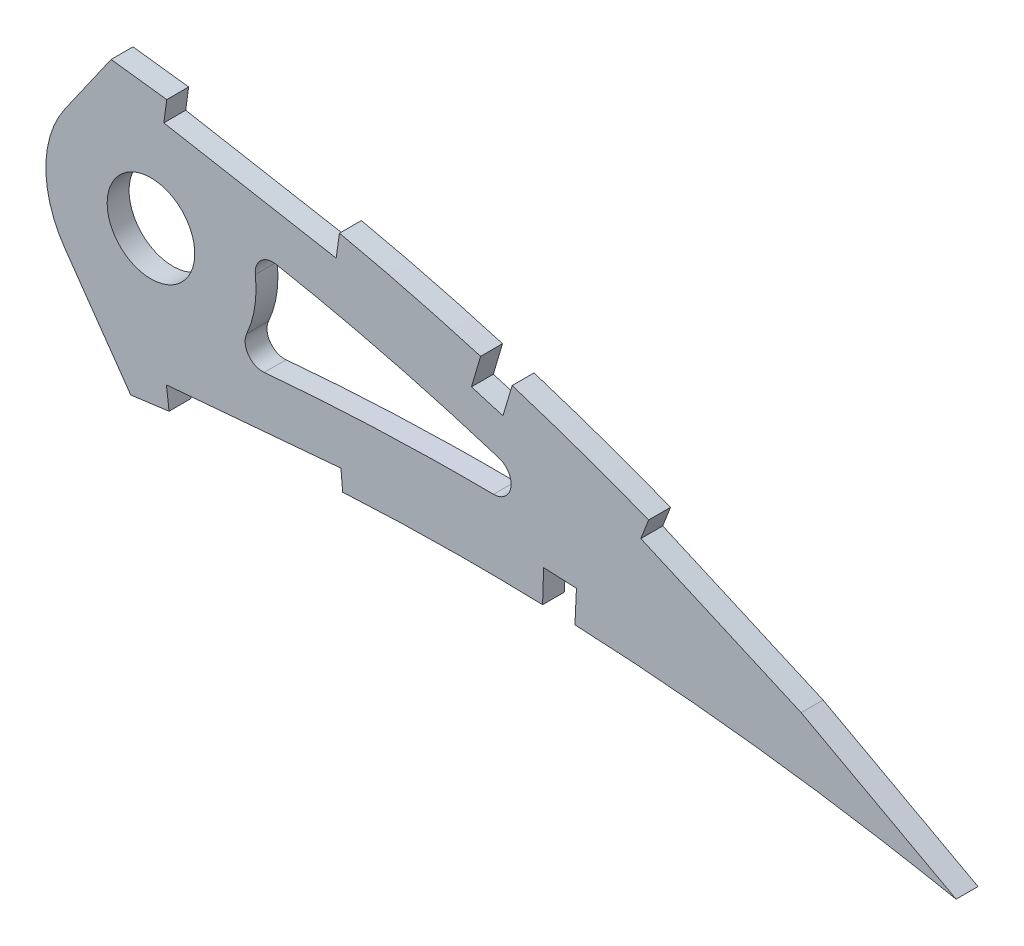
from build123d import *

# Parameters (mm, degrees)
BOSS_EXTRUDE1_DEPTH = 3.175
SKETCH3_R           = 6.35
CUT_EXTRUDE2_DEPTH  = 7.62
CUT_EXTRUDE6_DEPTH  = 408.776579698
CUT_EXTRUDE8_DEPTH  = 408.049338342
FILLET1_R           = 2.54


with BuildPart() as part:
    # Sketch1 → Boss-Extrude1 (new body)
    with BuildSketch(Plane.XY):
        with BuildLine():
            Line((400.787296687, -0.625618575), (404.58872131, -1.413553637))
            Line((404.58872131, -1.413553637), (401.287791605, 0.625618575))
            add(Edge.make_bspline(
                [(401.287791605, 0.625618575), (401.25705042, 0.644609155), (401.134204912, 0.72049782), (400.857411484, 0.890278961), (400.396493038, 1.173058239), (399.751247531, 1.566871371), (398.922175851, 2.070672454), (397.908860973, 2.68093382), (396.711935531, 3.395672751), (395.331689394, 4.211509244), (393.768263549, 5.124622449), (392.022253727, 6.13131418), (390.093811539, 7.225884301), (387.983684209, 8.40386082), (385.692595708, 9.659641163), (383.220979472, 10.987553753), (380.56972033, 12.38084365), (377.739836141, 13.833518373), (374.731843022, 15.337556147), (371.54715891, 16.88669721), (368.186844821, 18.473217451), (364.65204792, 20.088652961), (360.944798752, 21.726417866), (357.066122369, 23.376330622), (353.018229116, 25.031242761), (348.802842216, 26.681735695), (344.422457593, 28.32029276), (339.878765312, 29.936298907), (335.175161908, 31.522692312), (330.313928957, 33.069166923), (325.298542897, 34.56732415), (320.131917844, 36.007450609), (314.818360762, 37.382160583), (309.361241544, 38.681442748), (303.765185385, 39.896600345), (298.03464057, 41.02031727), (292.174413061, 42.04137478), (286.200742138, 42.958976846), (280.209742812, 43.722266376), (274.231069525, 44.470878511), (268.261299999, 45.17413112), (262.218567362, 45.847592765), (256.10868514, 46.487471701), (249.937713774, 47.091767095), (243.711900539, 47.657870828), (237.437715133, 48.184122735), (231.121228788, 48.667540922), (224.769101889, 49.107380553), (218.387614357, 49.499774963), (211.98356324, 49.844429477), (205.563449499, 50.138940399), (199.133954308, 50.381278445), (192.701904891, 50.569980712), (186.273977921, 50.703239355), (179.85713322, 50.780216544), (173.458045294, 50.79880892), (167.083670719, 50.758683916), (160.740684507, 50.658463796), (154.436050312, 50.496776579), (148.176452254, 50.273320497), (141.968659113, 49.988192458), (135.819467799, 49.639004764), (129.735549083, 49.227982621), (123.723677901, 48.753399501), (117.790459605, 48.215129125), (111.942112261, 47.615415217), (106.185147076, 46.95262669), (100.525733772, 46.228649337), (94.970062623, 45.44490258), (89.52436722, 44.600959597), (84.194481144, 43.69925796), (78.986156841, 42.740720338), (73.90490471, 41.728156841), (68.956256893, 40.661831591), (64.145451771, 39.544943342), (59.477489064, 38.379437887), (54.957386691, 37.167448987), (50.589726748, 35.911884874), (46.378925887, 34.615594017), (42.329892905, 33.280000791), (38.445687963, 31.910169164), (34.73108241, 30.507071575), (31.188921766, 29.075030523), (27.823357151, 27.616001391), (24.636902803, 26.134431982), (21.633165033, 24.632009073), (18.814284614, 23.11294194), (16.183091514, 21.579559842), (13.742118495, 20.034710979), (11.492391543, 18.482313842), (9.437012349, 16.923342928), (7.576687012, 15.361737611), (5.912592814, 13.799875814), (4.44710834, 12.23883351), (3.180180906, 10.681359637), (2.113470886, 9.128687662), (1.247163293, 7.582286813), (0.583217576, 6.043280407), (0.120975432, 4.512533928), (-0.132052878, 2.992306743), (-0.195033127, 1.481380095), (-0.064913904, 0.493055549), (0, 0)],
                knots=[0, 0, 0, 0, 0.00025409, 0.001015373, 0.002283359, 0.004056577, 0.006330981, 0.009105275, 0.01237449, 0.016134023, 0.020379661, 0.025105976, 0.030306237, 0.035972206, 0.042099523, 0.048678063, 0.055701664, 0.063160184, 0.071045824, 0.079349826, 0.08806291, 0.097175756, 0.106678112, 0.116561573, 0.126814275, 0.137428301, 0.148393618, 0.15969976, 0.171338125, 0.183297699, 0.195569604, 0.208143556, 0.221011593, 0.234161831, 0.24758745, 0.261276822, 0.27522271, 0.289414144, 0.3037712, 0.317689227, 0.331784111, 0.346039677, 0.36044387, 0.37498272, 0.389640454, 0.404403317, 0.419256601, 0.434186749, 0.449177265, 0.464214782, 0.479284009, 0.49436974, 0.509457833, 0.524532346, 0.53957932, 0.554582984, 0.569529546, 0.584403417, 0.599190992, 0.613876838, 0.628447475, 0.642888675, 0.657186054, 0.671325546, 0.685294014, 0.699078147, 0.712665095, 0.726042645, 0.739197713, 0.752117586, 0.764792042, 0.777208152, 0.789355685, 0.80122396, 0.812803686, 0.824082909, 0.835054602, 0.845709571, 0.856037853, 0.866033834, 0.875688843, 0.884997719, 0.893953426, 0.902552897, 0.910789386, 0.918660734, 0.926166253, 0.933302626, 0.94007122, 0.94647478, 0.952517526, 0.958204819, 0.963546652, 0.9685566, 0.973249913, 0.977651041, 0.981787043, 0.985694226, 0.989415109, 0.993001157, 0.996508416, 1, 1, 1, 1], degree=3))
            add(Edge.make_bspline(
                [(0, 0), (0.103049284, -0.48646135), (0.309621448, -1.461619734), (0.870851066, -2.865443777), (1.613050436, -4.214925318), (2.551796624, -5.50647982), (3.680847847, -6.739754318), (4.997710545, -7.916031475), (6.501093168, -9.034678962), (8.189028138, -10.095187575), (10.059063445, -11.09868312), (12.109097167, -12.044541691), (14.337260098, -12.932467688), (16.741124572, -13.761274257), (19.317751853, -14.532223507), (22.064692152, -15.243436854), (24.97882197, -15.895908217), (28.05733844, -16.487972167), (31.296886955, -17.020230139), (34.694102049, -17.492384374), (38.245496748, -17.904730047), (41.947586851, -18.256402054), (45.796710627, -18.548156683), (49.789031596, -18.780187571), (53.920674484, -18.953230456), (58.187681625, -19.066627473), (62.58587396, -19.122146552), (67.111276761, -19.120621113), (71.759463099, -19.061643238), (76.526462331, -18.948470974), (81.407699994, -18.780387546), (86.398769299, -18.559426901), (91.495168248, -18.287812779), (96.692325919, -17.966465898), (101.985668646, -17.596810448), (107.37060035, -17.181810955), (112.842229312, -16.722502456), (118.395783547, -16.221562258), (124.026346455, -15.681498051), (129.729053332, -15.104019149), (135.498870515, -14.49184199), (141.330658933, -13.846950334), (147.21945752, -13.172784637), (153.159886908, -12.470564744), (159.146923795, -11.74429993), (165.174935894, -10.995377793), (171.238882573, -10.22668305), (177.333309878, -9.441834962), (183.452512414, -8.640744143), (189.591343474, -7.829117957), (195.743882981, -7.00628799), (201.904775565, -6.176486019), (208.06831816, -5.342291406), (214.22850741, -4.503960799), (220.379928291, -3.664968493), (226.516874304, -2.827617677), (232.633334198, -1.991984907), (238.723774215, -1.162223511), (244.78206143, -0.338232212), (250.802609447, 0.478318572), (256.779648968, 1.284991388), (262.707540904, 2.080768094), (268.580170325, 2.865145364), (274.391628816, 3.638417632), (280.049067093, 4.37711422), (285.537702193, 5.120570933), (290.876029706, 5.730040641), (296.14788831, 6.250245022), (301.358754097, 6.676740793), (306.50237003, 7.015663982), (311.572842567, 7.269436368), (316.564128762, 7.441600876), (321.469923946, 7.537265082), (326.284100572, 7.558856566), (331.000087643, 7.513261133), (335.611751442, 7.404154135), (340.112655635, 7.236432817), (344.496521024, 7.015755786), (348.757120789, 6.748138962), (352.888058537, 6.437529801), (356.883577893, 6.091179644), (360.737514312, 5.714158782), (364.44395011, 5.310774515), (367.997477022, 4.889479588), (371.39240732, 4.453047621), (374.623634344, 4.008650917), (377.685956779, 3.560792785), (380.574524742, 3.11519123), (383.284799906, 2.676097091), (385.812404301, 2.249338393), (388.153378523, 1.838902367), (390.303660314, 1.448797258), (392.26026659, 1.083945061), (394.019333118, 0.746158195), (395.578507255, 0.441003535), (396.934889863, 0.169827429), (398.086492502, -0.063549443), (399.031304118, -0.25820606), (399.767889713, -0.41094701), (400.294794442, -0.522016373), (400.611448368, -0.58810827), (400.752141787, -0.618119663), (400.787296687, -0.625618575)],
                knots=[0, 0, 0, 0, 0.003638255, 0.007293231, 0.011028136, 0.014901081, 0.018963272, 0.023258475, 0.027820626, 0.032679082, 0.03785316, 0.043361875, 0.049214679, 0.055422346, 0.061988786, 0.068918036, 0.076211157, 0.083868392, 0.091887411, 0.100265912, 0.108999867, 0.118084529, 0.127514843, 0.13728527, 0.147387917, 0.157816481, 0.168563473, 0.179619128, 0.190977373, 0.202626974, 0.214560478, 0.226767249, 0.239236417, 0.251959004, 0.264923894, 0.278119703, 0.291536035, 0.30516028, 0.318980685, 0.332985499, 0.34716279, 0.361498603, 0.375980747, 0.390597192, 0.405332593, 0.420174823, 0.435109533, 0.450124276, 0.465203068, 0.480333154, 0.495500583, 0.510689775, 0.525887334, 0.541078314, 0.556247233, 0.571381784, 0.58646604, 0.601484516, 0.616424329, 0.631269422, 0.646006524, 0.660620684, 0.675098187, 0.689422858, 0.703581825, 0.716907563, 0.730009275, 0.742952128, 0.755725558, 0.768319952, 0.780724338, 0.792926529, 0.804916041, 0.816679084, 0.828203524, 0.8394749, 0.850481359, 0.861207697, 0.871639326, 0.881763414, 0.891563605, 0.901027365, 0.910138977, 0.918883977, 0.927249278, 0.935221104, 0.942784738, 0.949928188, 0.956638464, 0.962904203, 0.968712288, 0.974054485, 0.978918432, 0.983297218, 0.987180246, 0.990560674, 0.993433357, 0.995790625, 0.997629587, 0.998945816, 0.999736592, 1, 1, 1, 1], degree=3))
        make_face()
    extrude(amount=BOSS_EXTRUDE1_DEPTH)

    # Sketch3 → Cut-Extrude2 (cut)
    with BuildSketch(Plane(origin=(0, 0, 0), x_dir=(-1, 0, 0), z_dir=(0, 0, -1))):
        with Locations((-279.074525609, 26.255421435)):
            Circle(SKETCH3_R)
    extrude(amount=-CUT_EXTRUDE2_DEPTH, mode=Mode.SUBTRACT)

    # Sketch4 → Cut-Extrude6 (cut, through all)
    with BuildSketch(Plane.XY.offset(3.175)):
        with BuildLine():
            ThreePointArc((266.590648454, 17.514116545), (263.834525609, 26.255421435), (266.590648454, 34.996726325))
            Line((266.590648454, 34.996726325), (266.678819026, 35.122646952))
            Line((266.678819026, 35.122646952), (273.298363259, 44.576335854))
            add(Edge.make_bspline(
                [(273.298363259, 44.576335854), (271.627249364, 44.77745292), (267.942024962, 45.209714275), (262.218567362, 45.847592765), (256.10868514, 46.487471701), (249.937713774, 47.091767095), (243.711900539, 47.657870828), (237.437715133, 48.184122735), (231.121228788, 48.667540922), (224.769101889, 49.107380553), (218.387614357, 49.499774963), (211.98356324, 49.844429477), (205.563449499, 50.138940399), (199.133954308, 50.381278445), (192.701904891, 50.569980712), (186.273977921, 50.703239355), (179.85713322, 50.780216544), (173.458045294, 50.79880892), (167.083670719, 50.758683916), (161.240890559, 50.666367125), (157.524085212, 50.575387547), (155.922048169, 50.530055295)],
                knots=[0.31994822, 0.31994822, 0.31994822, 0.31994822, 0.331784111, 0.346039677, 0.36044387, 0.37498272, 0.389640454, 0.404403317, 0.419256601, 0.434186749, 0.449177265, 0.464214782, 0.479284009, 0.49436974, 0.509457833, 0.524532346, 0.53957932, 0.554582984, 0.569529546, 0.584403417, 0.595673217, 0.595673217, 0.595673217, 0.595673217], degree=3))
            add(Edge.make_bspline(
                [(155.922048169, 50.530055295), (155.421985617, 50.515905209), (152.834371808, 50.439599617), (148.176452254, 50.273320497), (141.968659113, 49.988192458), (135.819467799, 49.639004764), (129.735549083, 49.227982621), (123.723677901, 48.753399501), (117.790459605, 48.215129125), (111.942112261, 47.615415217), (106.185147076, 46.95262669), (100.525733772, 46.228649337), (94.970062623, 45.44490258), (89.52436722, 44.600959597), (84.194481144, 43.69925796), (78.986156841, 42.740720338), (73.90490471, 41.728156841), (68.956256893, 40.661831591), (64.145451771, 39.544943342), (59.477489064, 38.379437887), (54.957386691, 37.167448987), (50.589726748, 35.911884874), (46.378925887, 34.615594017), (42.329892905, 33.280000791), (38.445687963, 31.910169164), (34.73108241, 30.507071575), (31.188921766, 29.075030523), (27.823357151, 27.616001391), (24.636902803, 26.134431982), (21.633165033, 24.632009073), (18.814284614, 23.11294194), (16.183091514, 21.579559842), (13.742118495, 20.034710979), (11.492391543, 18.482313842), (9.437012349, 16.923342928), (7.576687012, 15.361737611), (5.912592814, 13.799875814), (4.44710834, 12.23883351), (3.180180906, 10.681359637), (2.113470886, 9.128687662), (1.247163293, 7.582286813), (0.583217576, 6.043280407), (0.120975432, 4.512533928), (-0.132052878, 2.992306743), (-0.195033127, 1.481380095), (-0.064913904, 0.493055549), (0, 0)],
                knots=[0.595673217, 0.595673217, 0.595673217, 0.595673217, 0.599190992, 0.613876838, 0.628447475, 0.642888675, 0.657186054, 0.671325546, 0.685294014, 0.699078147, 0.712665095, 0.726042645, 0.739197713, 0.752117586, 0.764792042, 0.777208152, 0.789355685, 0.80122396, 0.812803686, 0.824082909, 0.835054602, 0.845709571, 0.856037853, 0.866033834, 0.875688843, 0.884997719, 0.893953426, 0.902552897, 0.910789386, 0.918660734, 0.926166253, 0.933302626, 0.94007122, 0.94647478, 0.952517526, 0.958204819, 0.963546652, 0.9685566, 0.973249913, 0.977651041, 0.981787043, 0.985694226, 0.989415109, 0.993001157, 0.996508416, 1, 1, 1, 1], degree=3))
            add(Edge.make_bspline(
                [(0, 0), (0.103049284, -0.48646135), (0.309621448, -1.461619734), (0.870851066, -2.865443777), (1.613050436, -4.214925318), (2.551796624, -5.50647982), (3.680847847, -6.739754318), (4.997710545, -7.916031475), (6.501093168, -9.034678962), (8.189028138, -10.095187575), (10.059063445, -11.09868312), (12.109097167, -12.044541691), (14.337260098, -12.932467688), (16.741124572, -13.761274257), (19.317751853, -14.532223507), (22.064692152, -15.243436854), (24.97882197, -15.895908217), (28.05733844, -16.487972167), (31.296886955, -17.020230139), (34.694102049, -17.492384374), (38.245496748, -17.904730047), (41.947586851, -18.256402054), (45.796710627, -18.548156683), (49.789031596, -18.780187571), (53.920674484, -18.953230456), (58.187681625, -19.066627473), (62.58587396, -19.122146552), (67.111276761, -19.120621113), (71.759463099, -19.061643238), (76.526462331, -18.948470974), (81.407699994, -18.780387546), (86.398769299, -18.559426901), (91.495168248, -18.287812779), (96.692325919, -17.966465898), (101.985668646, -17.596810448), (107.37060035, -17.181810955), (112.842229312, -16.722502456), (118.395783547, -16.221562258), (124.026346455, -15.681498051), (129.729053332, -15.104019149), (135.498870515, -14.49184199), (141.330658933, -13.846950334), (147.21945752, -13.172784637), (153.159886908, -12.470564744), (159.146923795, -11.74429993), (165.087519012, -11.006238494), (169.031390588, -10.506510457), (170.965654904, -10.25953821)],
                knots=[0, 0, 0, 0, 0.003638255, 0.007293231, 0.011028136, 0.014901081, 0.018963272, 0.023258475, 0.027820626, 0.032679082, 0.03785316, 0.043361875, 0.049214679, 0.055422346, 0.061988786, 0.068918036, 0.076211157, 0.083868392, 0.091887411, 0.100265912, 0.108999867, 0.118084529, 0.127514843, 0.13728527, 0.147387917, 0.157816481, 0.168563473, 0.179619128, 0.190977373, 0.202626974, 0.214560478, 0.226767249, 0.239236417, 0.251959004, 0.264923894, 0.278119703, 0.291536035, 0.30516028, 0.318980685, 0.332985499, 0.34716279, 0.361498603, 0.375980747, 0.390597192, 0.405332593, 0.420174823, 0.434464025, 0.434464025, 0.434464025, 0.434464025], degree=3))
            add(Edge.make_bspline(
                [(170.965654904, -10.25953821), (171.053034392, -10.248381354), (173.172879776, -9.977620434), (177.333309878, -9.441834962), (183.452512414, -8.640744143), (189.591343474, -7.829117957), (195.743882981, -7.00628799), (201.904775565, -6.176486019), (208.06831816, -5.342291406), (214.22850741, -4.503960799), (220.379928291, -3.664968493), (226.516874304, -2.827617677), (232.633334198, -1.991984907), (238.723774215, -1.162223511), (244.78206143, -0.338232212), (250.802609447, 0.478318572), (256.779648968, 1.284991388), (262.707540904, 2.080768094), (268.580170325, 2.865145364), (273.053598122, 3.46037936), (275.569135879, 3.791009193), (276.146544657, 3.86688243)],
                knots=[0.434464025, 0.434464025, 0.434464025, 0.434464025, 0.435109533, 0.450124276, 0.465203068, 0.480333154, 0.495500583, 0.510689775, 0.525887334, 0.541078314, 0.556247233, 0.571381784, 0.58646604, 0.601484516, 0.616424329, 0.631269422, 0.646006524, 0.660620684, 0.675098187, 0.689422858, 0.693690448, 0.693690448, 0.693690448, 0.693690448], degree=3))
            Line((276.146544657, 3.86688243), (269.578307971, 13.247296561))
            Line((269.578307971, 13.247296561), (266.590648454, 17.514116545))
        make_face()
        with BuildLine():
            add(Edge.make_bspline(
                [(345.280778699, 17.138524199), (343.784100238, 17.712102169), (337.492980243, 20.063101429), (326.275084115, 23.810337857), (311.484657452, 27.867535323), (300.490953316, 30.234986898), (294.415102434, 31.333564105), (293.37827515, 31.514732137)],
                knots=[0.137249706, 0.137249706, 0.137249706, 0.137249706, 0.148918304, 0.18614788, 0.223377457, 0.260607033, 0.268267562, 0.268267562, 0.268267562, 0.268267562], degree=3))
            ThreePointArc((293.37827515, 31.514732137), (294.078637429, 28.926419094), (294.314525609, 26.255421435))
            ThreePointArc((294.314525609, 26.255421435), (293.254677636, 20.671436433), (290.222545491, 15.864114842))
            add(Edge.make_bspline(
                [(290.222545491, 15.864114842), (290.774126105, 15.922150342), (293.793472526, 16.232317616), (301.792459866, 16.94651902), (314.205368487, 17.632888547), (329.126934502, 17.796918069), (339.481884573, 17.460650141), (344.860745729, 17.16255365), (345.280778699, 17.138524199)],
                knots=[0.730956873, 0.730956873, 0.730956873, 0.730956873, 0.734905012, 0.752578011, 0.787924009, 0.823270008, 0.858616006, 0.861610406, 0.861610406, 0.861610406, 0.861610406], degree=3))
        make_face()
    extrude(amount=-CUT_EXTRUDE6_DEPTH, mode=Mode.SUBTRACT)

    # Sketch5 → Cut-Extrude8 (cut, through all)
    with BuildSketch(Plane.XY.offset(3.175)):
        with BuildLine():
            add(Edge.make_bspline(
                [(281.428214874, 43.565668026), (281.407899795, 43.568254047), (281.387584623, 43.570839337), (281.367269359, 43.57342392)],
                knots=[0.300745518, 0.300745518, 0.300745518, 0.300745518, 0.300889521, 0.300889521, 0.300889521, 0.300889521], degree=3))
            Line((281.367269359, 43.57342392), (280.936730544, 40.431239395))
            Line((280.936730544, 40.431239395), (305.92678033, 35.942589702))
            Line((305.92678033, 35.942589702), (306.369250913, 39.086545718))
            Line((306.369250913, 39.086545718), (281.428214874, 43.565668026))
        make_face()
        with BuildLine():
            add(Edge.make_bspline(
                [(306.410670798, 39.317183503), (305.540638719, 39.505504323), (302.765071766, 40.092715137), (298.03464057, 41.02031727), (292.174413061, 42.04137478), (286.626079059, 42.893641805), (283.026780842, 43.362177559), (281.428214874, 43.565668026)],
                knots=[0.241327911, 0.241327911, 0.241327911, 0.241327911, 0.24758745, 0.261276822, 0.27522271, 0.289414144, 0.300745518, 0.300745518, 0.300745518, 0.300745518], degree=3))
            Line((281.428214874, 43.565668026), (306.369250913, 39.086545718))
            Line((306.369250913, 39.086545718), (306.410670798, 39.317183503))
        make_face()
        with BuildLine():
            Line((330.109691414, 28.237455749), (331.441621686, 32.702939814))
            add(Edge.make_bspline(
                [(331.441621686, 32.702939814), (331.078592447, 32.816498368), (329.559030125, 33.288566804), (328.035627369, 33.748190522), (326.874240224, 34.090635015)],
                knots=[0.180622976, 0.180622976, 0.180622976, 0.180622976, 0.183297699, 0.191811938, 0.191811938, 0.191811938, 0.191811938], degree=3))
            Line((326.874240224, 34.090635015), (325.542932248, 29.587605098))
            Line((325.542932248, 29.587605098), (330.109691414, 28.237455749))
        make_face()
        with BuildLine():
            add(Edge.make_bspline(
                [(395.814804403, 0.393165288), (396.210888149, 0.314563813), (396.991244968, 0.158406842), (398.086492502, -0.063549443), (399.031304118, -0.25820606), (399.767889713, -0.41094701), (400.294794442, -0.522016373), (400.611448368, -0.58810827), (400.752141787, -0.618119663), (400.787296687, -0.625618575)],
                knots=[0.987601606, 0.987601606, 0.987601606, 0.987601606, 0.990560674, 0.993433357, 0.995790625, 0.997629587, 0.998945816, 0.999736592, 1, 1, 1, 1], degree=3))
            Line((395.814804403, 0.393165288), (440.773838235, -24.004450072))
            Line((440.773838235, -24.004450072), (440.773838235, 23.013704809))
            Line((440.773838235, 23.013704809), (353.171513036, 30.120841079))
            Line((353.171513036, 30.120841079), (351.257950572, 25.77342975))
            Line((351.257950572, 25.77342975), (352.514220741, 25.220468169))
            add(Edge.make_bspline(
                [(372.425416081, 16.456329436), (372.149331784, 16.589694647), (370.756527786, 17.259981448), (368.186844821, 18.473217451), (364.65204792, 20.088652961), (360.944798752, 21.726417866), (357.066122369, 23.376330622), (354.233510741, 24.534395589), (352.69682692, 25.147786694), (352.514220741, 25.220468169)],
                knots=[0.077193802, 0.077193802, 0.077193802, 0.077193802, 0.079349826, 0.08806291, 0.097175756, 0.106678112, 0.116561573, 0.126814275, 0.128196303, 0.128196303, 0.128196303, 0.128196303], degree=3))
            add(Edge.make_bspline(
                [(377.388746435, 14.004618579), (376.522002321, 14.442331967), (374.870914713, 15.266426229), (373.212680104, 16.076033878), (372.425416081, 16.456329436)],
                knots=[0.064217905, 0.064217905, 0.064217905, 0.064217905, 0.071045824, 0.077193802, 0.077193802, 0.077193802, 0.077193802], degree=3))
            add(Edge.make_bspline(
                [(393.939500934, 5.023132373), (393.901834139, 5.045017263), (393.282942705, 5.404442457), (392.022253727, 6.13131418), (390.093811539, 7.225884301), (387.983684209, 8.40386082), (385.692595708, 9.659641163), (383.220979472, 10.987553753), (380.56972033, 12.38084365), (378.603678585, 13.390078995), (377.523014718, 13.936811917), (377.388746435, 14.004618579)],
                knots=[0.020073331, 0.020073331, 0.020073331, 0.020073331, 0.020379661, 0.025105976, 0.030306237, 0.035972206, 0.042099523, 0.048678063, 0.055701664, 0.063160184, 0.064217905, 0.064217905, 0.064217905, 0.064217905], degree=3))
            Line((393.939500934, 5.023132373), (397.188135012, 3.26021805))
            Line((397.188135012, 3.26021805), (397.126933052, 3.147437315))
            add(Edge.make_bspline(
                [(401.287791605, 0.625618575), (401.25705042, 0.644609155), (401.134204912, 0.72049782), (400.857411484, 0.890278961), (400.396493038, 1.173058239), (399.751247531, 1.566871371), (398.922175851, 2.070672454), (398.027033708, 2.609765168), (397.407799236, 2.980044027), (397.126933052, 3.147437315)],
                knots=[0, 0, 0, 0, 0.00025409, 0.001015373, 0.002283359, 0.004056577, 0.006330981, 0.009105275, 0.011404455, 0.011404455, 0.011404455, 0.011404455], degree=3))
            Line((401.287791605, 0.625618575), (404.58872131, -1.413553637))
            Line((404.58872131, -1.413553637), (400.787296687, -0.625618575))
        make_face()
        with BuildLine():
            Line((373.349484248, 12.584268908), (395.673811049, 0.4696772))
            Line((395.673811049, 0.4696772), (397.126933052, 3.147437315))
            add(Edge.make_bspline(
                [(397.126933052, 3.147437315), (397.00843435, 3.218061294), (396.430462548, 3.562045925), (395.369191227, 4.189342645), (394.423884905, 4.741699076), (393.939500934, 5.023132373)],
                knots=[0.011404455, 0.011404455, 0.011404455, 0.011404455, 0.01237449, 0.016134023, 0.020073331, 0.020073331, 0.020073331, 0.020073331], degree=3))
            Line((393.939500934, 5.023132373), (377.388746435, 14.004618579))
            add(Edge.make_bspline(
                [(377.388746435, 14.004618579), (376.522002321, 14.442331967), (374.870914713, 15.266426229), (373.212680104, 16.076033878), (372.425416081, 16.456329436)],
                knots=[0.064217905, 0.064217905, 0.064217905, 0.064217905, 0.071045824, 0.077193802, 0.077193802, 0.077193802, 0.077193802], degree=3))
            Line((372.425416081, 16.456329436), (352.514220741, 25.220468169))
            add(Edge.make_bspline(
                [(352.514220741, 25.220468169), (352.089508725, 25.389513355), (351.664409047, 25.557584831), (351.23892744, 25.724684222)],
                knots=[0.128196303, 0.128196303, 0.128196303, 0.128196303, 0.131410673, 0.131410673, 0.131410673, 0.131410673], degree=3))
            Line((351.23892744, 25.724684222), (350.103842034, 22.816102297))
            Line((350.103842034, 22.816102297), (373.349484248, 12.584268908))
        make_face()
        with BuildLine():
            Line((395.673811049, 0.4696772), (395.814804403, 0.393165288))
            add(Edge.make_bspline(
                [(395.814804403, 0.393165288), (396.210888149, 0.314563813), (396.991244968, 0.158406842), (398.086492502, -0.063549443), (399.031304118, -0.25820606), (399.767889713, -0.41094701), (400.294794442, -0.522016373), (400.611448368, -0.58810827), (400.752141787, -0.618119663), (400.787296687, -0.625618575)],
                knots=[0.987601606, 0.987601606, 0.987601606, 0.987601606, 0.990560674, 0.993433357, 0.995790625, 0.997629587, 0.998945816, 0.999736592, 1, 1, 1, 1], degree=3))
            Line((400.787296687, -0.625618575), (404.58872131, -1.413553637))
            Line((404.58872131, -1.413553637), (401.287791605, 0.625618575))
            add(Edge.make_bspline(
                [(401.287791605, 0.625618575), (401.25705042, 0.644609155), (401.134204912, 0.72049782), (400.857411484, 0.890278961), (400.396493038, 1.173058239), (399.751247531, 1.566871371), (398.922175851, 2.070672454), (398.027033708, 2.609765168), (397.407799236, 2.980044027), (397.126933052, 3.147437315)],
                knots=[0, 0, 0, 0, 0.00025409, 0.001015373, 0.002283359, 0.004056577, 0.006330981, 0.009105275, 0.011404455, 0.011404455, 0.011404455, 0.011404455], degree=3))
            Line((397.126933052, 3.147437315), (395.673811049, 0.4696772))
        make_face()
        with BuildLine():
            Line((336.009855475, 12.126080058), (335.858239577, 7.386225856))
            add(Edge.make_bspline(
                [(335.858239577, 7.386225856), (337.289289331, 7.34162077), (338.853707711, 7.282840149), (340.417651806, 7.213286538), (340.551262365, 7.207265816)],
                knots=[0.83998973, 0.83998973, 0.83998973, 0.83998973, 0.850481359, 0.851461433, 0.851461433, 0.851461433, 0.851461433], degree=3))
            Line((340.551262365, 7.207265816), (340.766842537, 11.907878281))
            Line((340.766842537, 11.907878281), (336.009855475, 12.126080058))
        make_face()
        with BuildLine():
            add(Edge.make_bspline(
                [(335.858239577, 7.386225856), (337.289289331, 7.34162077), (338.853707711, 7.282840149), (340.417651806, 7.213286538), (340.551262365, 7.207265816)],
                knots=[0.83998973, 0.83998973, 0.83998973, 0.83998973, 0.850481359, 0.851461433, 0.851461433, 0.851461433, 0.851461433], degree=3))
            Line((335.858239577, 7.386225856), (335.85760715, 7.366454764))
            Line((335.85760715, 7.366454764), (340.550184528, 7.18376416))
            Line((340.550184528, 7.18376416), (340.551262365, 7.207265816))
        make_face()
        with BuildLine():
            Line((306.870874942, 7.023333218), (306.620105016, 9.916850496))
            Line((306.620105016, 9.916850496), (281.320380386, 7.726901793))
            Line((281.320380386, 7.726901793), (281.698025793, 4.601592598))
            add(Edge.make_bspline(
                [(281.698025793, 4.601592598), (282.988303862, 4.773678863), (286.051202377, 5.179196562), (290.876029706, 5.730040641), (296.14788831, 6.250245022), (301.358754097, 6.676740793), (304.927097687, 6.911866122), (306.756925365, 7.016855557), (306.870874942, 7.023333218)],
                knots=[0.707368902, 0.707368902, 0.707368902, 0.707368902, 0.716907563, 0.730009275, 0.742952128, 0.755725558, 0.768319952, 0.769156305, 0.769156305, 0.769156305, 0.769156305], degree=3))
        make_face()
        with BuildLine():
            add(Edge.make_bspline(
                [(397.126933052, 3.147437315), (397.00843435, 3.218061294), (396.430462548, 3.562045925), (395.369191227, 4.189342645), (394.423884905, 4.741699076), (393.939500934, 5.023132373)],
                knots=[0.011404455, 0.011404455, 0.011404455, 0.011404455, 0.01237449, 0.016134023, 0.020073331, 0.020073331, 0.020073331, 0.020073331], degree=3))
            Line((397.126933052, 3.147437315), (397.188135012, 3.26021805))
            Line((397.188135012, 3.26021805), (393.939500934, 5.023132373))
        make_face()
        with BuildLine():
            Line((377.388746435, 14.004618579), (393.939500934, 5.023132373))
            add(Edge.make_bspline(
                [(393.939500934, 5.023132373), (393.901834139, 5.045017263), (393.282942705, 5.404442457), (392.022253727, 6.13131418), (390.093811539, 7.225884301), (387.983684209, 8.40386082), (385.692595708, 9.659641163), (383.220979472, 10.987553753), (380.56972033, 12.38084365), (378.603678585, 13.390078995), (377.523014718, 13.936811917), (377.388746435, 14.004618579)],
                knots=[0.020073331, 0.020073331, 0.020073331, 0.020073331, 0.020379661, 0.025105976, 0.030306237, 0.035972206, 0.042099523, 0.048678063, 0.055701664, 0.063160184, 0.064217905, 0.064217905, 0.064217905, 0.064217905], degree=3))
        make_face()
        with BuildLine():
            add(Edge.make_bspline(
                [(372.425416081, 16.456329436), (372.149331784, 16.589694647), (370.756527786, 17.259981448), (368.186844821, 18.473217451), (364.65204792, 20.088652961), (360.944798752, 21.726417866), (357.066122369, 23.376330622), (354.233510741, 24.534395589), (352.69682692, 25.147786694), (352.514220741, 25.220468169)],
                knots=[0.077193802, 0.077193802, 0.077193802, 0.077193802, 0.079349826, 0.08806291, 0.097175756, 0.106678112, 0.116561573, 0.126814275, 0.128196303, 0.128196303, 0.128196303, 0.128196303], degree=3))
            Line((352.514220741, 25.220468169), (372.425416081, 16.456329436))
        make_face()
    extrude(amount=-CUT_EXTRUDE8_DEPTH, mode=Mode.SUBTRACT)

    # Fillet1
    fillet1_edges = [part.edges().sort_by_distance(p)[0] for p in [
        (345.280778699, 17.138524199, 1.5875),
        (293.37827515, 31.514732137, 1.5875),
        (290.222545491, 15.864114842, 1.5875),
    ]]
    fillet(fillet1_edges, radius=FILLET1_R)


solid = part.part
